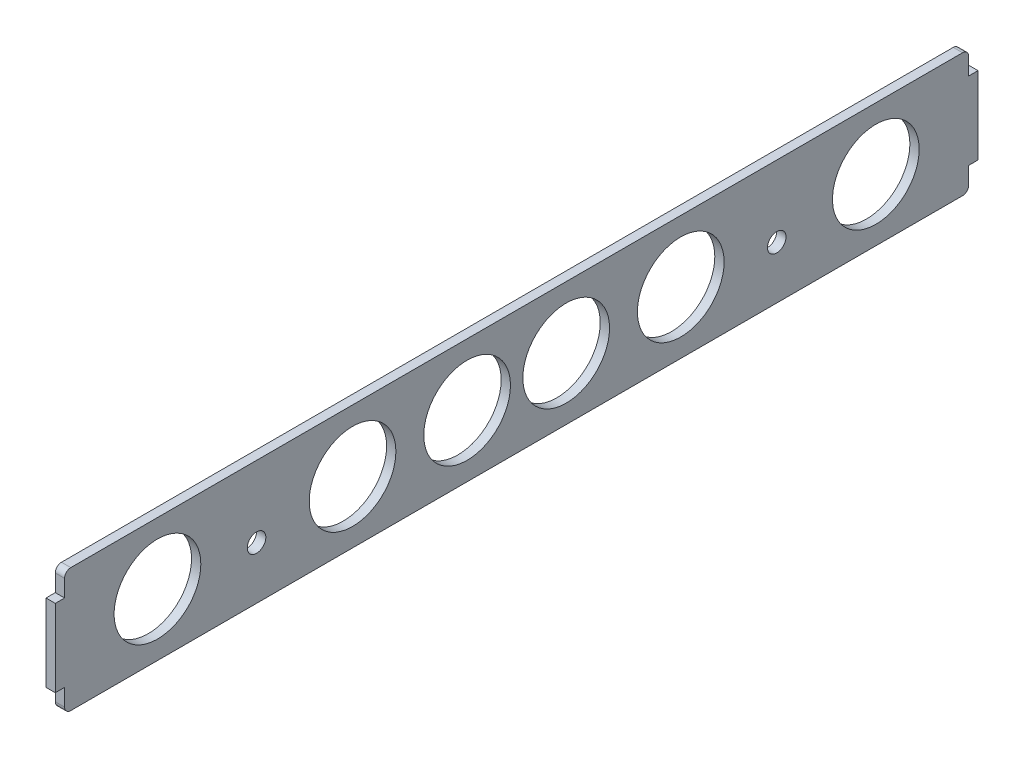
from build123d import *

# Parameters (mm, degrees)
SKETCH3_W           = 292
SKETCH3_H           = 40
SKETCH3_R           = 3
BOSS_EXTRUDE2_DEPTH = 3
FILLET1_R           = 2
SKETCH4_R           = 14
CUT_EXTRUDE1_DEPTH  = 10
SKETCH5_W           = 3
SKETCH5_H           = 25
BOSS_EXTRUDE3_DEPTH = 3


with BuildPart() as part:
    # Sketch3 → Boss-Extrude2 (new body)
    with BuildSketch(Plane(origin=(0, 0, 0), x_dir=(0, 0, -1), z_dir=(1, 0, 0))):
        with Locations((146, -20)):
            Rectangle(SKETCH3_W, SKETCH3_H)
        with Locations((62, -23)):
            Circle(SKETCH3_R, mode=Mode.SUBTRACT)
        with Locations((230, -23)):
            Circle(SKETCH3_R, mode=Mode.SUBTRACT)
    extrude(amount=BOSS_EXTRUDE2_DEPTH)

    # Fillet1
    fillet1_edges = [part.edges().sort_by_distance(p)[0] for p in [
        (1.5, -40, -292),
        (1.5, -40, 0),
        (1.5, 0, 0),
        (1.5, 0, -292),
    ]]
    fillet(fillet1_edges, radius=FILLET1_R)

    # Sketch4 → Cut-Extrude1 (cut)
    with BuildSketch(Plane(origin=(3, 0, 0), x_dir=(0, 0, -1), z_dir=(1, 0, 0))):
        with Locations((30, -20)):
            Circle(SKETCH4_R)
        with Locations((93, -20)):
            Circle(SKETCH4_R)
        with Locations((130, -20)):
            Circle(SKETCH4_R)
        with Locations((162, -20)):
            Circle(SKETCH4_R)
        with Locations((199, -20)):
            Circle(SKETCH4_R)
        with Locations((262, -20)):
            Circle(SKETCH4_R)
    extrude(amount=-CUT_EXTRUDE1_DEPTH, mode=Mode.SUBTRACT)

    # Sketch5 → Boss-Extrude3 (add)
    with BuildSketch(Plane(origin=(3, 0, 0), x_dir=(0, 0, -1), z_dir=(1, 0, 0))):
        with Locations((-1.5, -20)):
            Rectangle(SKETCH5_W, SKETCH5_H)
        with Locations((293.5, -20)):
            Rectangle(SKETCH5_W, SKETCH5_H)
    extrude(amount=-BOSS_EXTRUDE3_DEPTH)


solid = part.part
